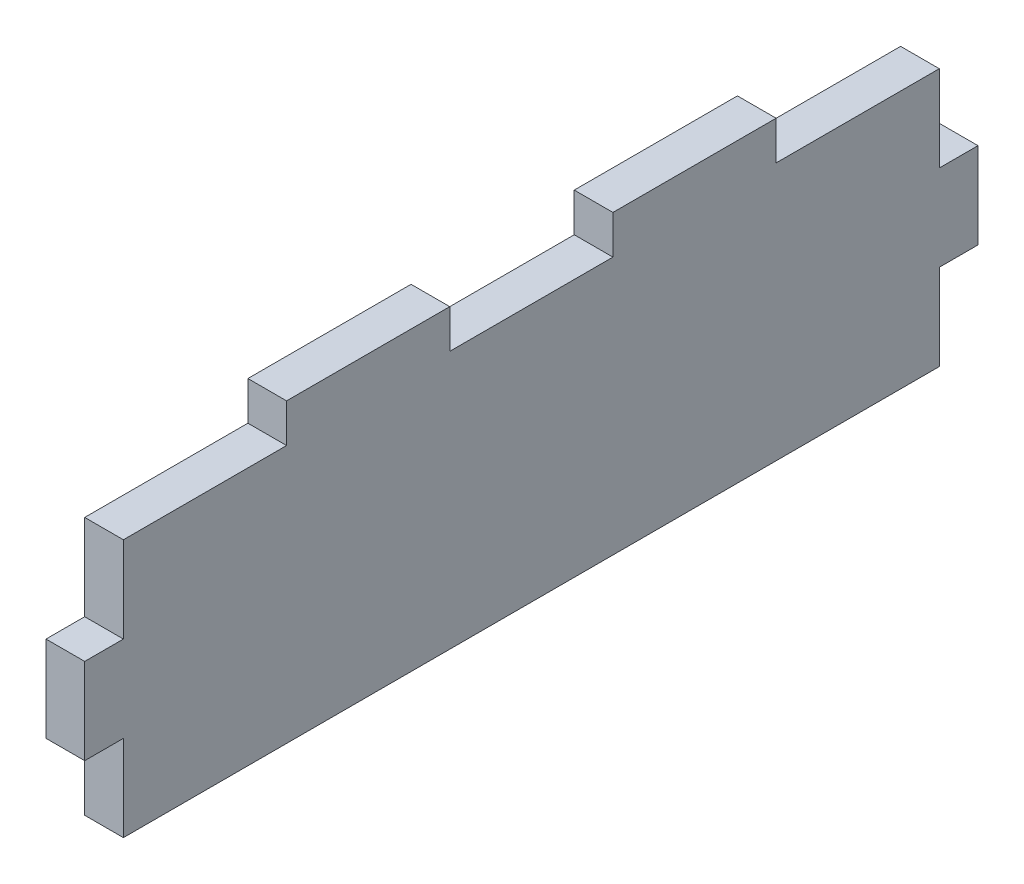
from build123d import *

# Parameters (mm, degrees)
SKETCH1_W               = 415
SKETCH1_H               = 126.5
BOSS_EXTRUDE1_DEPTH     = 6
SKETCH2_W               = 6
SKETCH2_H               = 126.5
BOSS_EXTRUDE2_DEPTH     = 40
CUT_EXTRUDE1_DEPTH      = 226.252774678
CUT_EXTRUDE1_DEPTH_BACK = 226.252774678
SKETCH1_2_W             = 415
SKETCH1_2_H             = 126.5
SKETCH2_4_W             = 6
SKETCH2_4_H             = 25.3
BOSS_EXTRUDE3_DEPTH     = 6
SKETCH6_W               = 6
SKETCH6_H               = 13.333333334
BOSS_EXTRUDE5_DEPTH     = 6


with BuildPart() as part:
    # Sketch1 → Boss-Extrude1 (new body)
    with BuildSketch(Plane(origin=(0, 0, 0), x_dir=(1, 0, 0), z_dir=(0, 1, 0))):
        Rectangle(SKETCH1_W, SKETCH1_H)
    extrude(amount=BOSS_EXTRUDE1_DEPTH)

    # Sketch2 → Boss-Extrude2 (add)
    with BuildSketch(Plane(origin=(0, 6, 0), x_dir=(1, 0, 0), z_dir=(0, 1, 0))):
        with Locations((-210.5, 0)):
            Rectangle(SKETCH2_W, SKETCH2_H)
    extrude(amount=-BOSS_EXTRUDE2_DEPTH)

    # Sketch1_2 → Cut-Extrude1 (cut, two sides: drawn at the far end of the back side and taken through both)
    with BuildSketch(Plane(origin=(0, 0, 0), x_dir=(1, 0, 0), z_dir=(0, 1, 0)).offset(-CUT_EXTRUDE1_DEPTH_BACK)):
        Rectangle(SKETCH1_2_W, SKETCH1_2_H)
    extrude(amount=CUT_EXTRUDE1_DEPTH + CUT_EXTRUDE1_DEPTH_BACK, mode=Mode.SUBTRACT)

    # Sketch2_4 → Boss-Extrude3 (add)
    with BuildSketch(Plane(origin=(0, 6, 0), x_dir=(1, 0, 0), z_dir=(0, 1, 0))):
        with Locations((-210.5, -25.3)):
            Rectangle(SKETCH2_4_W, SKETCH2_4_H)
        with Locations((-210.5, 25.3)):
            Rectangle(SKETCH2_4_W, SKETCH2_4_H)
    extrude(amount=BOSS_EXTRUDE3_DEPTH)

    # Sketch6 → Boss-Extrude5 (add)
    with BuildSketch(Plane.XY.offset(63.25)):
        with Locations((-210.5, -14)):
            Rectangle(SKETCH6_W, SKETCH6_H)
    boss_extrude5 = extrude(amount=BOSS_EXTRUDE5_DEPTH)

    # Mirror4: Boss-Extrude5 across plane
    add(boss_extrude5.mirror(Plane.XY))


solid = part.part
